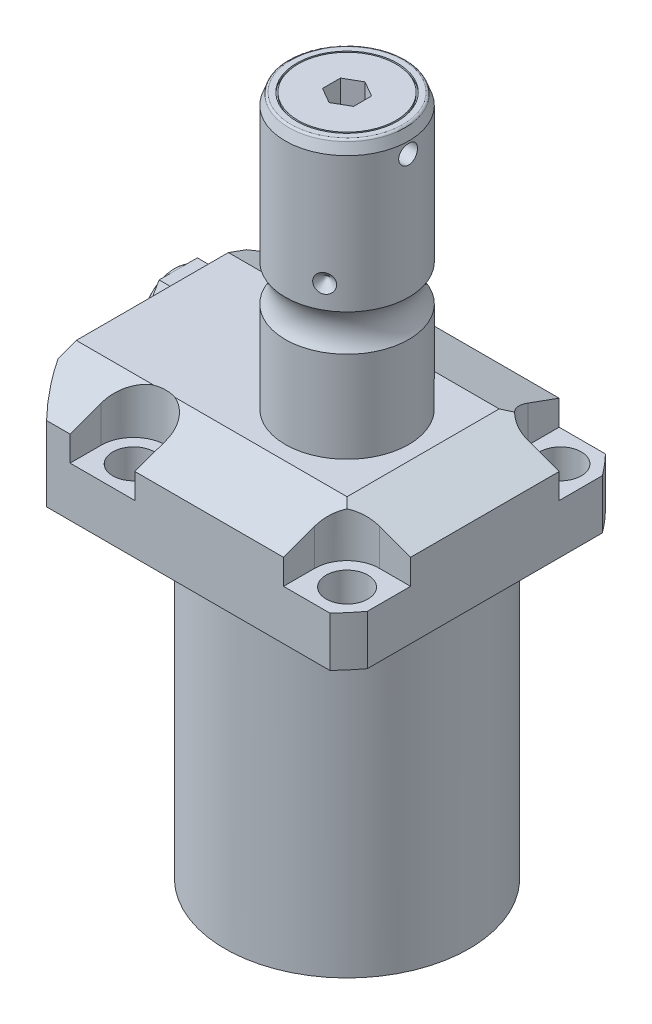
from build123d import *

# Parameters (mm, degrees)
SKETCH1_W               = 70.866
SKETCH1_H               = 85.496
EXTRUDE1_DEPTH          = 104.521
SKETCH2_OUTSIDE_W       = 117.996
SKETCH2_OUTSIDE_H       = 103.366
SKETCH2_OUTSIDE_R       = 50.8
CUT_EXTRUDE1_DEPTH      = 105.521
SKETCH3_W               = 45.1992
SKETCH3_H               = 79.502
FILLET1_R               = 0.381
CUT_EXTRUDE2_DEPTH      = 12.243
CUT_EXTRUDE9_START      = -51.063
CUT_EXTRUDE9_DEPTH      = 87.496
CUT_EXTRUDE7_DEPTH      = 36.433
CUT_EXTRUDE7_DEPTH_BACK = 36.433
SKETCH10_R              = 1.1811
SKETCH17_W              = 5.3594
SKETCH17_H              = 12.776
HOLE1_AT_2_COUNT        = 2
HOLE1_AT_2_PITCH        = 54.864
HOLE1_AT_3_COUNT        = 2
HOLE1_AT_3_PITCH        = 77.589412886
HOLE1_AT_4_COUNT        = 2
HOLE1_AT_4_PITCH        = 54.864
CHAMFER1_SIZE           = 0.635
EXTRUDE2_DEPTH          = 7.874
SKETCH23_W              = 1
SKETCH23_H              = 1.651
FILLET2_R               = 0.635
SKETCH24_R              = 12.954
SKETCH24_R_2            = 12.573
CUT_EXTRUDE10_DEPTH     = 0.49999999
CUT_EXTRUDE11_DEPTH     = 8
CIRPATTERN1_COUNT       = 3
SKETCH27_W              = 3.81
SKETCH27_H              = 2.413


with BuildPart() as part:
    # Sketch1 → Extrude1 (new body)
    with BuildSketch(Plane(origin=(0, 0, 0), x_dir=(0, 0, 1), z_dir=(0, -1, 0))):
        with Locations((0, 7.315)):
            Rectangle(SKETCH1_W, SKETCH1_H)
    extrude(amount=-EXTRUDE1_DEPTH)

    # Sketch2 outside → Cut-Extrude1 (cut, through all)
    with BuildSketch(Plane.XZ):
        with Locations((-7.315, 0)):
            Rectangle(SKETCH2_OUTSIDE_W, SKETCH2_OUTSIDE_H)
        with Locations((-5.4102, 0)):
            Circle(SKETCH2_OUTSIDE_R, mode=Mode.SUBTRACT)
    extrude(amount=-CUT_EXTRUDE1_DEPTH, mode=Mode.SUBTRACT)

    # Sketch3 → Cut-Revolve1 (revolve, cut)
    with BuildSketch(Plane(origin=(0, 0, 0), x_dir=(0, 0, -1), z_dir=(1, 0, 0))):
        with Locations((53.9941, 39.751)):
            Rectangle(SKETCH3_W, SKETCH3_H)
    revolve(axis=Axis((0, -93.345, 0), (0, 1, 0)), mode=Mode.SUBTRACT)

    # Fillet1
    fillet1_edges = [part.edges().sort_by_distance(p)[0] for p in [
        (0, 79.502, 31.3945),
    ]]
    fillet(fillet1_edges, radius=FILLET1_R)

    # Sketch4 → Cut-Extrude2 (cut)
    with BuildSketch(Plane(origin=(0, 104.521, 0), x_dir=(-1, 0, 0), z_dir=(0, 1, 0))):
        with BuildLine():
            Line((-19.1008, -35.433), (-19.1008, -27.432))
            ThreePointArc((-19.1008, -27.432), (-21.540951985, -21.540951985), (-27.432, -19.1008))
            Line((-27.432, -19.1008), (-35.433, -19.1008))
            Line((-35.433, -19.1008), (-35.433, -35.433))
            Line((-35.433, -35.433), (-19.1008, -35.433))
        make_face()
        with BuildLine():
            Line((35.7632, -35.433), (19.1008, -35.433))
            Line((19.1008, -35.433), (19.1008, -27.432))
            ThreePointArc((19.1008, -27.432), (27.432, -19.1008), (35.7632, -27.432))
            Line((35.7632, -27.432), (35.7632, -35.433))
        make_face()
        with BuildLine():
            Line((19.1008, 35.433), (19.1008, 27.432))
            ThreePointArc((19.1008, 27.432), (27.432, 19.1008), (35.7632, 27.432))
            Line((35.7632, 27.432), (35.7632, 35.433))
            Line((35.7632, 35.433), (19.1008, 35.433))
        make_face()
        with BuildLine():
            Line((-27.432, 19.1008), (-35.433, 19.1008))
            Line((-35.433, 19.1008), (-35.433, 35.433))
            Line((-35.433, 35.433), (-19.1008, 35.433))
            Line((-19.1008, 35.433), (-19.1008, 27.432))
            ThreePointArc((-19.1008, 27.432), (-21.540951985, 21.540951985), (-27.432, 19.1008))
        make_face()
    extrude(amount=-CUT_EXTRUDE2_DEPTH, mode=Mode.SUBTRACT)

    # Sketch5 → Cut-Extrude9 (cut)
    with BuildSketch(Plane(origin=(0, 0, 0), x_dir=(0, 0, -1), z_dir=(1, 0, 0)).offset(CUT_EXTRUDE9_START)):
        Polygon((-19.558, 104.521), (-35.433, 98.742972531), (-35.433, 104.521), align=None)
    cut_extrude9 = extrude(amount=CUT_EXTRUDE9_DEPTH, mode=Mode.SUBTRACT)

    # Mirror1: Cut-Extrude9 across plane
    add(cut_extrude9.mirror(Plane.XY), mode=Mode.SUBTRACT)

    # Sketch9 → Cut-Extrude7 (cut, two sides)
    with BuildSketch(Plane.XY) as cut_extrude7_sk:
        Polygon((19.558, 104.521), (35.433, 98.742972531), (35.433, 104.521), align=None)
    extrude(amount=CUT_EXTRUDE7_DEPTH, mode=Mode.SUBTRACT)
    extrude(cut_extrude7_sk.sketch, amount=-CUT_EXTRUDE7_DEPTH_BACK, mode=Mode.SUBTRACT)

    # Sketch20 → Cut-Revolve4 (revolve, cut)
    with BuildSketch(Plane(origin=(-35.0774, 88.9, -18.1102), x_dir=(0, 1, 0), z_dir=(1, 0, 0)), mode=Mode.PRIVATE) as cut_revolve4_sk:
        Polygon((-9.398, 38.3413), (-7.9502, 38.3413), (-7.9502, 35.8902), (-6.9342, 35.8902), (-6.9342, 33.8836), (4.0386, 33.8836), (4.0386, 32.639), (-9.398, 32.639), align=None)
    cut_revolve4 = revolve(cut_revolve4_sk.sketch.rotate(Axis((-35.0774, 81.620304954, 14.5288), (0, 1, 0)), 180), axis=Axis((-35.0774, 81.620304954, 14.5288), (0, 1, 0)), mode=Mode.SUBTRACT)  # turned: the seam where the file's is

    # Mirror10: Cut-Revolve4 across plane
    add(cut_revolve4.mirror(Plane.XY), mode=Mode.SUBTRACT)

    # Sketch15 → Revolve3 (revolve)
    with BuildSketch(Plane(origin=(0, 0, 0), x_dir=(0, 0, -1), z_dir=(1, 0, 0)), mode=Mode.PRIVATE) as revolve3_sk:
        with BuildLine():
            Line((0, 104.521), (15.875, 104.521))
            Line((15.875, 104.521), (15.875, 127.90490643))
            ThreePointArc((15.875, 127.90490643), (14.3256, 132.612), (15.875, 137.31909357))
            Line((15.875, 137.31909357), (15.875, 172.10899416))
            Line((15.875, 172.10899416), (14.81184082, 175.03))
            Line((14.81184082, 175.03), (0, 175.03))
            Line((0, 175.03), (0, 104.521))
        make_face()
    revolve(revolve3_sk.sketch.rotate(Axis((0, 250.290824608, 0), (0, -1, 0)), 180), axis=Axis((0, 250.290824608, 0), (0, -1, 0)))  # turned: the seam where the file's is

    # Sketch17 → Hole1 (revolve, cut)
    with BuildSketch(Plane(origin=(27.432, 92.278, -27.432), x_dir=(0, 0, 1), z_dir=(1, 0, 0))):
        with Locations((2.6797, 6.388)):
            Rectangle(SKETCH17_W, SKETCH17_H)
    hole1 = revolve(axis=Axis((27.432, -17.722, -27.432), (0, 1, 0)), mode=Mode.SUBTRACT)

    # Hole1 at 2: Hole1 ×2
    with Locations(*[(0, 0, i * HOLE1_AT_2_PITCH) for i in range(1, HOLE1_AT_2_COUNT)]):
        add(hole1, mode=Mode.SUBTRACT)

    # Hole1 at 3: Hole1 ×2
    with Locations(*[Vector(-0.707106781, 0, 0.707106781) * (i * HOLE1_AT_3_PITCH) for i in range(1, HOLE1_AT_3_COUNT)]):
        add(hole1, mode=Mode.SUBTRACT)

    # Hole1 at 4: Hole1 ×2
    with Locations(*[(-i * HOLE1_AT_4_PITCH, 0, 0) for i in range(1, HOLE1_AT_4_COUNT)]):
        add(hole1, mode=Mode.SUBTRACT)

    # Chamfer1
    chamfer1_edges = [part.edges().sort_by_distance(p)[0] for p in [
        (-35.0774, 81.9658, 15.7734),
        (-35.0774, 81.9658, -15.7734),
    ]]
    chamfer(chamfer1_edges, length=CHAMFER1_SIZE)

    # Sketch21 → Cut-Revolve5 (revolve, cut)
    with BuildSketch(Plane.XZ.offset(-92.5068)):
        Polygon((-50.063, -1.9304), (-49.809, -1.9304), (-49.809, -6.3246), (-49.0978, -7.0358), (-35.6358, -7.0358), (-35.6358, -12.9794), (-50.063, -12.9794), align=None)
    cut_revolve5 = revolve(axis=Axis((-57.549532301, 92.5068, -12.9794), (1, 0, 0)), mode=Mode.SUBTRACT)

    # Mirror13: Cut-Revolve5 across plane
    add(cut_revolve5.mirror(Plane.XY), mode=Mode.SUBTRACT)

    # Sketch22 → Extrude2 (add)
    with BuildSketch(Plane.ZY.offset(49.809)):
        Polygon((-3.154053119, 92.5068), (-8.066726559, 101.0158), (-17.892073441, 101.0158), (-22.804746881, 92.5068), (-17.892073441, 83.9978), (-8.066726559, 83.9978), align=None)
    extrude(amount=EXTRUDE2_DEPTH)

    # Sketch23 → Cut-Revolve6 (revolve, cut)
    with BuildSketch(Plane.XZ.offset(-92.5068)):
        with BuildLine():
            Line((-57.683, -2.8194), (-56.383, -2.8194))
            Line((-56.383, -2.8194), (-56.383, -4.4704))
            Line((-56.383, -4.4704), (-56.413, -4.4704))
            ThreePointArc((-56.413, -4.4704), (-57.311025612, -4.842374388), (-57.683, -5.7404))
            Line((-57.683, -5.7404), (-57.683, -2.8194))
        make_face()
        with Locations((-50.309, -3.6449)):
            Rectangle(SKETCH23_W, SKETCH23_H)
    revolve(axis=Axis((-77.466597129, 92.5068, -12.9794), (1, 0, 0)), mode=Mode.SUBTRACT)

    # Fillet2
    fillet2_edges = [part.edges().sort_by_distance(p)[0] for p in [
        (0, 175.03, -14.81184082),
    ]]
    fillet(fillet2_edges, radius=FILLET2_R)

    # Sketch24 → Cut-Extrude10 (cut)
    with BuildSketch(Plane(origin=(0, 175.03, 0), x_dir=(1, 0, 0), z_dir=(0, 1, 0))):
        with Locations(Location((0, 0, 0), (0, 0, 270))):  # turned: the seam where the file's is
            Circle(SKETCH24_R)
        with Locations(Location((0, 0, 0), (0, 0, 270))):  # turned: the seam where the file's is
            Circle(SKETCH24_R_2, mode=Mode.SUBTRACT)
    extrude(amount=-CUT_EXTRUDE10_DEPTH, mode=Mode.SUBTRACT)

    # Sketch25 → Cut-Extrude11 (cut)
    with BuildSketch(Plane(origin=(0, 175.03, 0), x_dir=(1, 0, 0), z_dir=(0, 1, 0))):
        Polygon((4, -2.309401077), (4, 2.309401077), (0, 4.618802154), (-4, 2.309401077), (-4, -2.309401077), (0, -4.618802154), align=None)
    extrude(amount=-CUT_EXTRUDE11_DEPTH, mode=Mode.SUBTRACT)

    # Sketch26 → Cut-Revolve7 (revolve, cut)
    with BuildSketch(Plane.XY, mode=Mode.PRIVATE) as cut_revolve7_sk:
        Polygon((-15.875, 145.713), (-13.462, 143.3), (-15.875, 143.3), align=None)
    cut_revolve7 = revolve(cut_revolve7_sk.sketch.rotate(Axis((-39.772000707, 143.3, 0), (1, 0, 0)), 90), axis=Axis((-39.772000707, 143.3, 0), (1, 0, 0)), mode=Mode.SUBTRACT)  # turned: the seam where the file's is

    # CirPattern1: Cut-Revolve7 ×3 about axis
    cirpattern1_axis = Axis((0, 250.290824608, 0), (0, 1, 0))
    for i in range(1, CIRPATTERN1_COUNT):
        add(cut_revolve7.rotate(cirpattern1_axis, i * 360 / CIRPATTERN1_COUNT), mode=Mode.SUBTRACT)

    # Sketch27 → Cut-Revolve8 (revolve, cut)
    with BuildSketch(Plane.XY, mode=Mode.PRIVATE) as cut_revolve8_sk:
        with Locations((13.97, 170.3945)):
            Rectangle(SKETCH27_W, SKETCH27_H)
    revolve(cut_revolve8_sk.sketch.rotate(Axis((5.37407372, 169.188, 0), (1, 0, 0)), 90), axis=Axis((5.37407372, 169.188, 0), (1, 0, 0)), mode=Mode.SUBTRACT)  # turned: the seam where the file's is


with BuildPart() as body_2:
    # Sketch10 → Revolve4 (revolve)
    with BuildSketch(Plane(origin=(-35.0774, 88.9, -18.1102), x_dir=(0, 1, 0), z_dir=(1, 0, 0))):
        with Locations((-9.1313, 8.1026)):
            Circle(SKETCH10_R)
    revolve(axis=Axis((-35.0774, 87.86749, -14.5288), (0, 1, 0)))


with BuildPart() as body_3:
    # Mirror12: mirrored copy
    add(body_2.part.mirror(Plane.XY))


solid = Compound([part.part, body_2.part, body_3.part])
